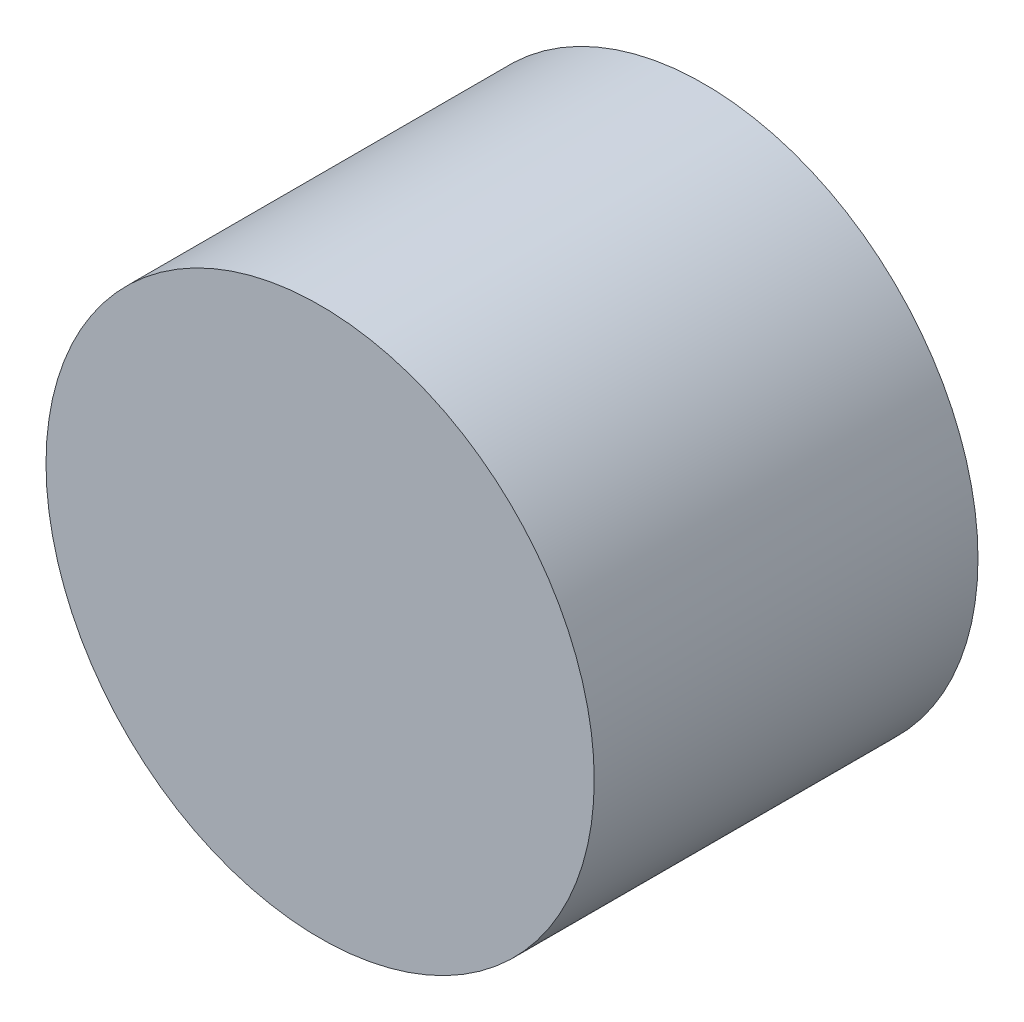
from build123d import *


with BuildPart() as part:
    # Sketch1 → Revolve2 (revolve)
    with BuildSketch(Plane(origin=(0, 0, 0), x_dir=(1, 0, 0), z_dir=(0, 1, 0))):
        Polygon((-5, 0), (-1.55, 0), (-1.55, 2), align=None)
        Polygon((-1.55, -5), (-1.55, 0), (-5, 0), (-5, -7), (0, -7), (0, -5), align=None)
    revolve(axis=Axis((0, 0, 0), (0, 0, 1)))


solid = part.part
